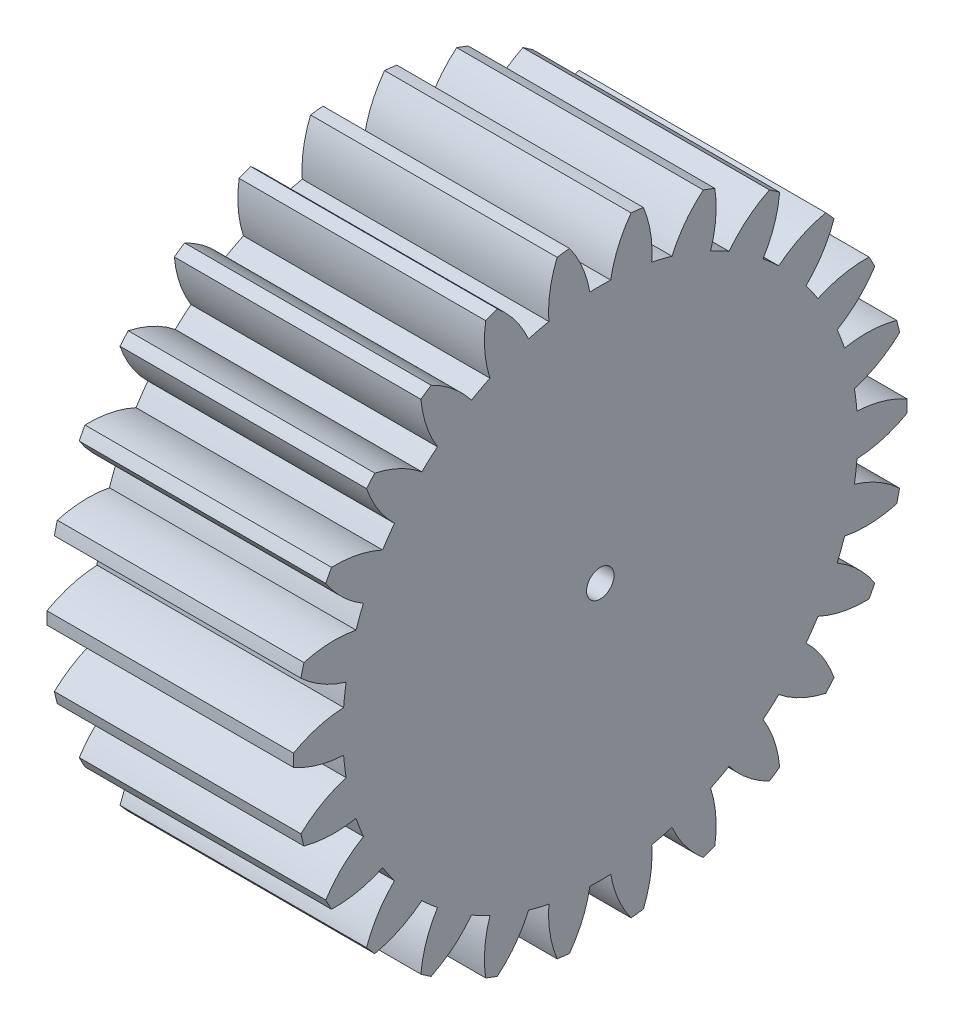
from build123d import *

# Parameters (mm, degrees)
BASPROSKE_W     = 9
BASPROSKE_H     = 11.2
TOOTHCUT_DEPTH  = 19.217573933
TEETHCUTS_COUNT = 26
TEETHCUTS_ANGLE = 346.153846154
BORSKE_R        = 0.5
BORE_DEPTH      = 50.0000508


with BuildPart() as part:
    # BasProSke → Base-Revolve (revolve)
    with BuildSketch(Plane(origin=(0, 0, 0), x_dir=(1, 0, 0), z_dir=(0, 1, 0)), mode=Mode.PRIVATE) as base_revolve_sk:
        with Locations((4.5, 5.6)):
            Rectangle(BASPROSKE_W, BASPROSKE_H)
    revolve(base_revolve_sk.sketch.rotate(Axis((-10, 0, 0), (1, 0, 0)), 180), axis=Axis((-10, 0, 0), (1, 0, 0)))

    # TooCutSke → ToothCut (cut, through all)
    with BuildSketch(Plane(origin=(0, 0, 0), x_dir=(0, 0, -1), z_dir=(1, 0, 0))):
        with BuildLine():
            ThreePointArc((0.380904725, 9.391278539), (0, 9.399), (-0.380904725, 9.391278539))
            ThreePointArc((-0.380904725, 9.391278539), (-0.656954926, 10.324018205), (-1.142064934, 11.167152405))
            ThreePointArc((-1.142064934, 11.167152405), (0, 11.2254), (1.142064934, 11.167152405))
            ThreePointArc((1.142064934, 11.167152405), (0.656954926, 10.324018205), (0.380904725, 9.391278539))
        make_face()
    toothcut = extrude(amount=TOOTHCUT_DEPTH, mode=Mode.SUBTRACT)

    # TeethCuts: ToothCut ×26 about axis
    teethcuts_axis = Axis((-10, 0, 0), (1, 0, 0))
    for i in range(1, TEETHCUTS_COUNT):
        add(toothcut.rotate(teethcuts_axis, i * TEETHCUTS_ANGLE / (TEETHCUTS_COUNT - 1)), mode=Mode.SUBTRACT)

    # BorSke → Bore (cut, symmetric)
    with BuildSketch(Plane(origin=(0, 0, 0), x_dir=(0, 0, -1), z_dir=(1, 0, 0))):
        with Locations(Location((0, 0, 0), (0, 0, 180))):
            Circle(BORSKE_R)
    extrude(amount=BORE_DEPTH, both=True, mode=Mode.SUBTRACT)


solid = part.part
